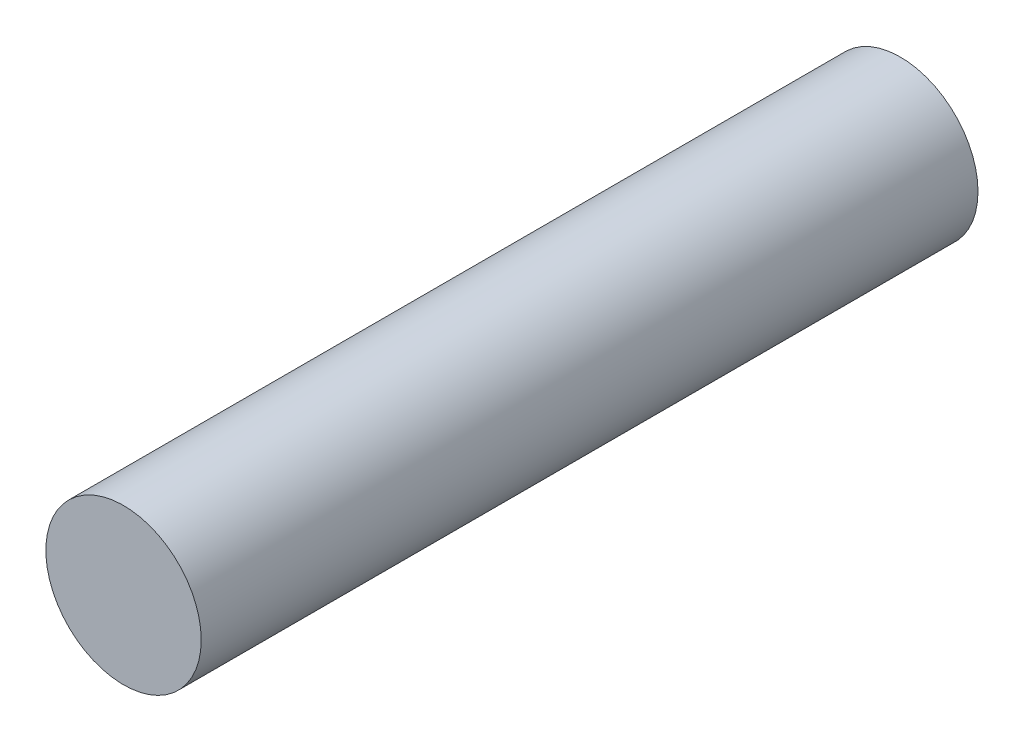
from build123d import *

# Parameters (mm, degrees)
ESQUISSE1_R        = 3
BOSS_EXTRU_1_DEPTH = 30


with BuildPart() as part:
    # Esquisse1 → Boss.-Extru.1 (new body)
    with BuildSketch(Plane.XY):
        Circle(ESQUISSE1_R)
    extrude(amount=BOSS_EXTRU_1_DEPTH)


solid = part.part
